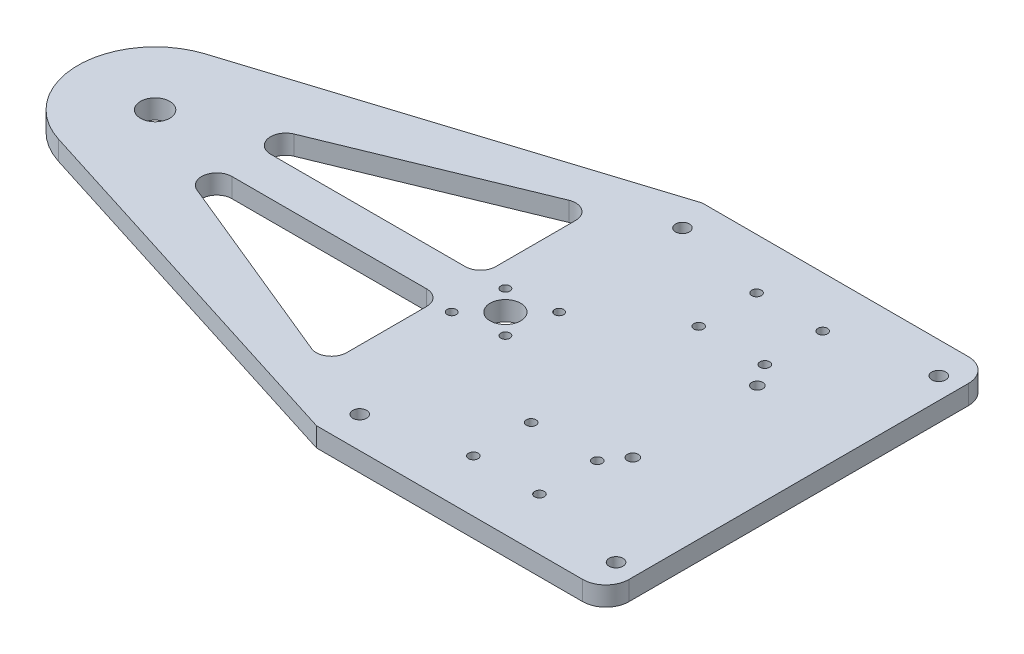
from build123d import *

# Parameters (mm, degrees)
SKETCH1_W           = 95.25
SKETCH1_H           = 127
BOSS_EXTRUDE1_DEPTH = 6.35
BOSS_EXTRUDE3_DEPTH = 6.35
SKETCH5_R           = 4.826
SKETCH5_R_2         = 5.039999953
SKETCH5_R_3         = 1.5
CUT_EXTRUDE1_DEPTH  = 7.35
CUT_EXTRUDE2_DEPTH  = 7.35
FILLET9_R           = 5
FILLET10_R          = 7.62
SKETCH7_R           = 2.2812375
CUT_EXTRUDE3_DEPTH  = 7.35
SKETCH8_R           = 1.5875
CUT_EXTRUDE4_DEPTH  = 7.35
SKETCH9_R           = 1.830008083
CUT_EXTRUDE5_DEPTH  = 7.35


with BuildPart() as part:
    # Sketch1 → Boss-Extrude1 (new body)
    with BuildSketch(Plane(origin=(0, 0, 0), x_dir=(1, 0, 0), z_dir=(0, 1, 0))):
        Rectangle(SKETCH1_W, SKETCH1_H)
    extrude(amount=BOSS_EXTRUDE1_DEPTH)

    # Sketch4 → Boss-Extrude3 (add)
    with BuildSketch(Plane(origin=(0, 6.35, 0), x_dir=(1, 0, 0), z_dir=(0, 1, 0))):
        with BuildLine():
            Line((-47.625, 63.5), (-171.916018217, 24.219268021))
            ThreePointArc((-171.916018217, 24.219268021), (-189.6618, 0), (-171.916018217, -24.219268021))
            Line((-171.916018217, -24.219268021), (-47.625, -63.5))
            Line((-47.625, -63.5), (-47.625, 63.5))
        make_face()
    extrude(amount=-BOSS_EXTRUDE3_DEPTH)

    # Sketch5 → Cut-Extrude1 (cut, through all)
    with BuildSketch(Plane(origin=(0, 6.35, 0), x_dir=(1, 0, 0), z_dir=(0, 1, 0))):
        with Locations((-164.2618, 0)):
            Circle(SKETCH5_R)
        with Locations((-48.9458, 0)):
            Circle(SKETCH5_R_2)
        with Locations((-40.106965235, 8.838834765)):
            Circle(SKETCH5_R_3)
        with Locations((-57.784634765, -8.838834765)):
            Circle(SKETCH5_R_3)
        with Locations((-55.663314421, 6.717514421)):
            Circle(SKETCH5_R_3)
        with Locations((-42.228285579, -6.717514421)):
            Circle(SKETCH5_R_3)
    extrude(amount=-CUT_EXTRUDE1_DEPTH, mode=Mode.SUBTRACT)

    # Sketch6 → Cut-Extrude2 (cut, through all)
    with BuildSketch(Plane(origin=(0, 6.35, 0), x_dir=(1, 0, 0), z_dir=(0, 1, 0))):
        Polygon((-63.5, 45.163743355), (-157.9118, 6.35), (-63.5, 6.35), align=None)
        Polygon((-63.5, -6.35), (-63.5, -45.163743355), (-157.9118, -6.35), align=None)
    extrude(amount=-CUT_EXTRUDE2_DEPTH, mode=Mode.SUBTRACT)

    # Fillet9
    fillet9_edges = [part.edges().sort_by_distance(p)[0] for p in [
        (-63.5, 3.175, -45.163743355),
        (-63.5, 3.175, -6.35),
        (-157.9118, 3.175, -6.35),
        (-157.9118, 3.175, 6.35),
        (-63.5, 3.175, 6.35),
        (-63.5, 3.175, 45.163743355),
    ]]
    fillet(fillet9_edges, radius=FILLET9_R)

    # Fillet10
    fillet10_edges = [part.edges().sort_by_distance(p)[0] for p in [
        (47.625, 3.175, 63.5),
        (47.625, 3.175, -63.5),
    ]]
    fillet(fillet10_edges, radius=FILLET10_R)

    # Sketch7 → Cut-Extrude3 (cut, through all)
    with BuildSketch(Plane(origin=(0, 6.35, 0), x_dir=(1, 0, 0), z_dir=(0, 1, 0))):
        with Locations((-43.777254611, -53.125383493)):
            Circle(SKETCH7_R)
        with Locations((-43.777254611, 53.125383493)):
            Circle(SKETCH7_R)
        with Locations((40.602254611, 53.125383493)):
            Circle(SKETCH7_R)
        with Locations((40.602254611, -53.125383493)):
            Circle(SKETCH7_R)
    extrude(amount=-CUT_EXTRUDE3_DEPTH, mode=Mode.SUBTRACT)

    # Sketch8 → Cut-Extrude4 (cut, through all)
    with BuildSketch(Plane(origin=(0, 6.35, 0), x_dir=(1, 0, 0), z_dir=(0, 1, 0))):
        with Locations((-13.209796215, -27.25)):
            Circle(SKETCH8_R)
        with Locations((8.564628211, -27.25)):
            Circle(SKETCH8_R)
        with Locations((8.564628211, -46.3)):
            Circle(SKETCH8_R)
        with Locations((-13.209796215, -46.3)):
            Circle(SKETCH8_R)
        with Locations((8.717854945, 46.8)):
            Circle(SKETCH8_R)
        with Locations((-13.056569481, 27.75)):
            Circle(SKETCH8_R)
        with Locations((-13.056569481, 46.8)):
            Circle(SKETCH8_R)
        with Locations((8.717854945, 27.75)):
            Circle(SKETCH8_R)
    extrude(amount=-CUT_EXTRUDE4_DEPTH, mode=Mode.SUBTRACT)

    # Sketch9 → Cut-Extrude5 (cut, through all)
    with BuildSketch(Plane(origin=(0, 6.35, 0), x_dir=(1, 0, 0), z_dir=(0, 1, 0))):
        with Locations((13.499388849, -20.49783886)):
            Circle(SKETCH9_R)
        with Locations((13.49951585, 20.502576943)):
            Circle(SKETCH9_R)
    extrude(amount=-CUT_EXTRUDE5_DEPTH, mode=Mode.SUBTRACT)


solid = part.part
